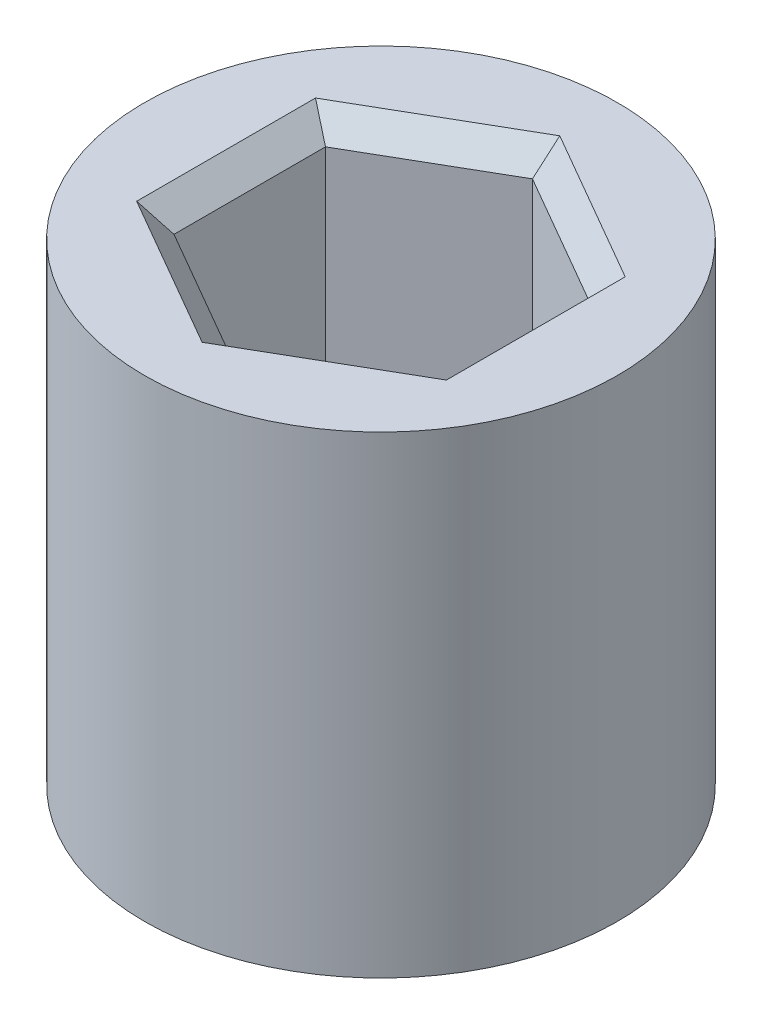
from build123d import *

# Parameters (mm, degrees)
SKETCH1_R           = 5
BOSS_EXTRUDE1_DEPTH = 10
CUT_EXTRUDE1_DEPTH  = 6.6
CHAMFER1_SIZE       = 0.5


with BuildPart() as part:
    # Sketch1 → Boss-Extrude1 (new body)
    with BuildSketch(Plane(origin=(0, 0, 0), x_dir=(1, 0, 0), z_dir=(0, 1, 0))):
        with Locations(Location((0, 0, 0), (0, 0, 270))):
            Circle(SKETCH1_R)
        Polygon((2.775, -1.602146997), (2.775, 1.602146997), (0, 3.204293994), (-2.775, 1.602146997), (-2.775, -1.602146997), (0, -3.204293994), align=None, mode=Mode.SUBTRACT)
        Polygon((0, -3.204293994), (2.775, -1.602146997), (2.775, 1.602146997), (0, 3.204293994), (-2.775, 1.602146997), (-2.775, -1.602146997), align=None)
    extrude(amount=BOSS_EXTRUDE1_DEPTH)

    # Sketch2 → Cut-Extrude1 (cut)
    with BuildSketch(Plane(origin=(0, 10, 0), x_dir=(1, 0, 0), z_dir=(0, 1, 0))):
        Polygon((-2.775, -1.602146997), (0, -3.204293994), (2.775, -1.602146997), (2.775, 1.602146997), (0, 3.204293994), (-2.775, 1.602146997), align=None)
    extrude(amount=-CUT_EXTRUDE1_DEPTH, mode=Mode.SUBTRACT)

    # Chamfer1
    chamfer1_edges = [part.edges().sort_by_distance(p)[0] for p in [
        (-2.775, 10, 0),
        (-1.3875, 10, 2.403220496),
        (1.3875, 10, 2.403220496),
        (2.775, 10, 0),
        (1.3875, 10, -2.403220496),
        (-1.3875, 10, -2.403220496),
    ]]
    chamfer(chamfer1_edges, length=CHAMFER1_SIZE)


solid = part.part
